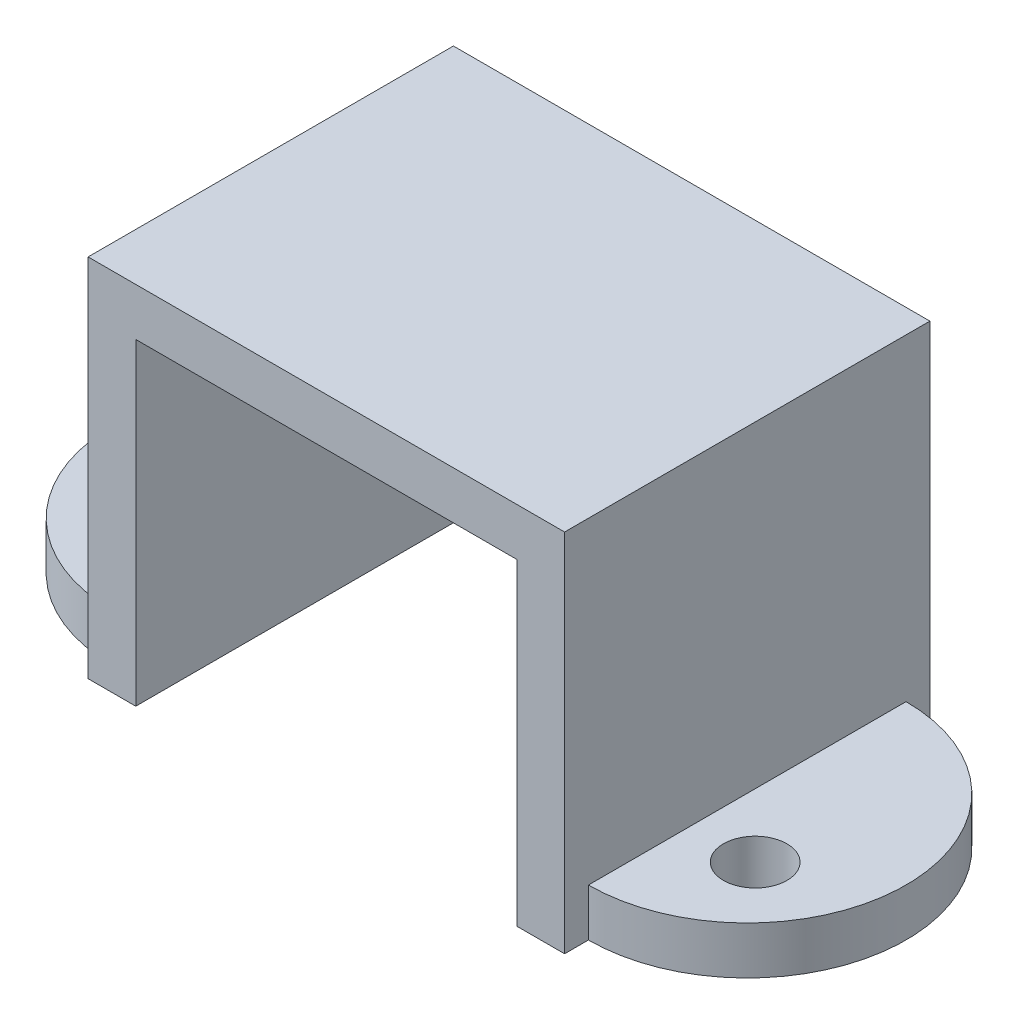
from build123d import *

# Parameters (mm, degrees)
BOSS_EXTRUDE1_DEPTH = 11.5
SKETCH2_R           = 1
BOSS_EXTRUDE2_DEPTH = 1.5


with BuildPart() as part:
    # Sketch1 → Boss-Extrude1 (new body)
    with BuildSketch(Plane.XY):
        Polygon((7.5, 5.75), (-7.5, 5.75), (-7.5, -5.75), (-6, -5.75), (-6, 4.25), (6, 4.25), (6, -5.75), (7.5, -5.75), align=None)
    extrude(amount=-BOSS_EXTRUDE1_DEPTH)

    # Sketch2 → Boss-Extrude2 (add)
    with BuildSketch(Plane.XZ.offset(5.75)):
        with BuildLine():
            Line((-7.5, -10.75), (-7.5, -0.75))
            ThreePointArc((-7.5, -0.75), (-12.5, -5.75), (-7.5, -10.75))
        make_face()
        with Locations((-9.5, -4)):
            Circle(SKETCH2_R, mode=Mode.SUBTRACT)
        with BuildLine():
            Line((7.5, -0.75), (7.5, -10.75))
            ThreePointArc((7.5, -10.75), (12.5, -5.75), (7.5, -0.75))
        make_face()
        with Locations((9.5, -4)):
            Circle(SKETCH2_R, mode=Mode.SUBTRACT)
    extrude(amount=-BOSS_EXTRUDE2_DEPTH)


solid = part.part
